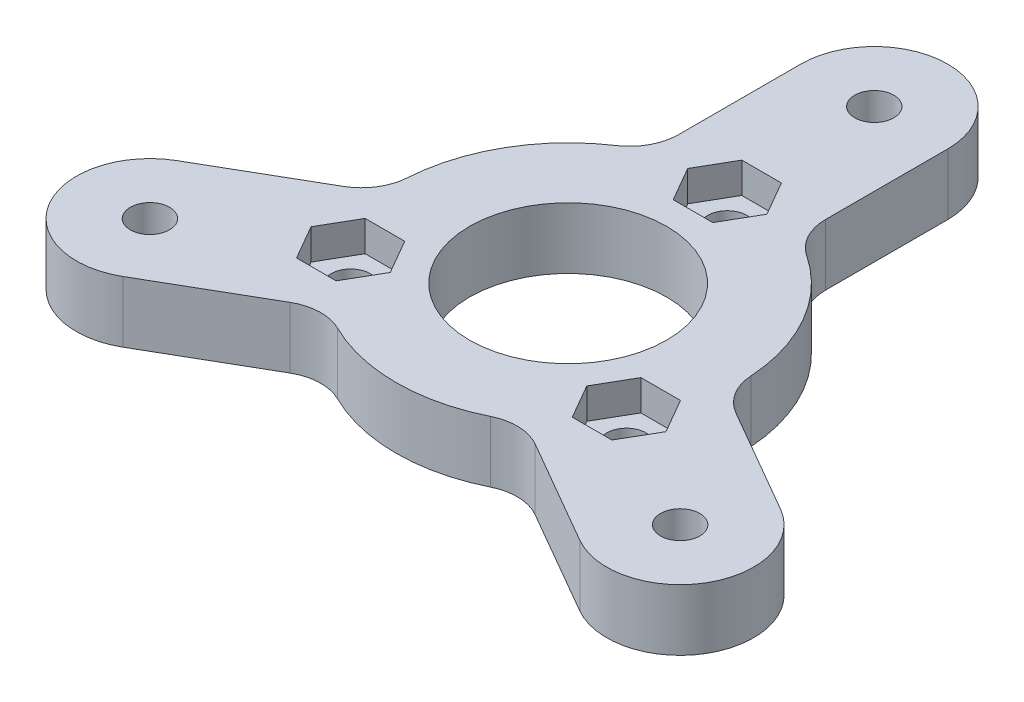
from build123d import *

# Parameters (mm, degrees)
SKETCH1_R           = 8.05
SKETCH1_R_2         = 1.6
BOSS_EXTRUDE1_DEPTH = 5
CUT_EXTRUDE1_DEPTH  = 2.5
CUT_EXTRUDE2_REACH  = 4.5
SKETCH4_R           = 1.6


with BuildPart() as part:
    # Sketch1 → Boss-Extrude1 (new body)
    with BuildSketch(Plane(origin=(0, 0, 0), x_dir=(1, 0, 0), z_dir=(0, 1, 0))):
        with BuildLine():
            Line((24.650635095, -7.303847577), (16.013526617, -2.317210672))
            ThreePointArc((16.013526617, -2.317210672), (14.614747196, -0.962208024), (14.021609361, 0.892732285))
            ThreePointArc((14.021609361, 0.892732285), (12.167656923, 7.025), (7.783933518, 11.696703766))
            ThreePointArc((7.783933518, 11.696703766), (6.474077005, 13.137846354), (6, 15.02672619))
            Line((6, 15.02672619), (6, 25))
            ThreePointArc((6, 25), (0, 31), (-6, 25))
            Line((-6, 25), (-6, 15.02672619))
            ThreePointArc((-6, 15.02672619), (-6.474077005, 13.137846354), (-7.783933518, 11.696703766))
            ThreePointArc((-7.783933518, 11.696703766), (-12.167656923, 7.025), (-14.021609361, 0.892732285))
            ThreePointArc((-14.021609361, 0.892732285), (-14.614747196, -0.962208024), (-16.013526617, -2.317210672))
            Line((-16.013526617, -2.317210672), (-24.650635095, -7.303847577))
            ThreePointArc((-24.650635095, -7.303847577), (-26.846787517, -15.5), (-18.650635095, -17.696152423))
            Line((-18.650635095, -17.696152423), (-10.013526617, -12.709515518))
            ThreePointArc((-10.013526617, -12.709515518), (-8.140670191, -12.17563833), (-6.237675843, -12.589436051))
            ThreePointArc((-6.237675843, -12.589436051), (0, -14.05), (6.237675843, -12.589436051))
            ThreePointArc((6.237675843, -12.589436051), (8.140670191, -12.17563833), (10.013526617, -12.709515518))
            Line((10.013526617, -12.709515518), (18.650635095, -17.696152423))
            ThreePointArc((18.650635095, -17.696152423), (26.846787517, -15.5), (24.650635095, -7.303847577))
        make_face()
        Circle(SKETCH1_R, mode=Mode.SUBTRACT)
        with Locations((0, 25)):
            Circle(SKETCH1_R_2, mode=Mode.SUBTRACT)
        with Locations((21.650635095, -12.5)):
            Circle(SKETCH1_R_2, mode=Mode.SUBTRACT)
        with Locations((-21.650635095, -12.5)):
            Circle(SKETCH1_R_2, mode=Mode.SUBTRACT)
    extrude(amount=BOSS_EXTRUDE1_DEPTH)

    # Sketch3 → Cut-Extrude1 (cut)
    with BuildSketch(Plane(origin=(0, 5, 0), x_dir=(1, 0, 0), z_dir=(0, 1, 0))):
        Polygon((1.616580754, 15.8), (-1.616580754, 15.8), (-3.233161507, 13), (-1.616580754, 10.2), (1.616580754, 10.2), (3.233161507, 13), align=None)
        Polygon((-8.025168742, -6.5), (-9.641749495, -3.7), (-12.874911003, -3.7), (-14.491491757, -6.5), (-12.874911003, -9.3), (-9.641749495, -9.3), align=None)
        Polygon((14.491491757, -6.5), (12.874911003, -3.7), (9.641749495, -3.7), (8.025168742, -6.5), (9.641749495, -9.3), (12.874911003, -9.3), align=None)
    extrude(amount=-CUT_EXTRUDE1_DEPTH, mode=Mode.SUBTRACT)

    # Sketch4 → Cut-Extrude2 (cut, up to next)
    with BuildSketch(Plane(origin=(0, 2.5, 0), x_dir=(1, 0, 0), z_dir=(0, 1, 0)), mode=Mode.PRIVATE) as cut_extrude2_sk1:
        with Locations((0, 13)):
            Circle(SKETCH4_R)
    cut_extrude2_tool1 = extrude(cut_extrude2_sk1.sketch, amount=-CUT_EXTRUDE2_REACH, mode=Mode.PRIVATE) & part.part
    add(cut_extrude2_tool1.solids().sort_by_distance((0, 2.5, -13))[0], mode=Mode.SUBTRACT)
    # Sketch4 → Cut-Extrude2 (cut, up to next)
    with BuildSketch(Plane(origin=(0, 2.5, 0), x_dir=(1, 0, 0), z_dir=(0, 1, 0)), mode=Mode.PRIVATE) as cut_extrude2_sk2:
        with Locations((11.258330249, -6.5)):
            Circle(SKETCH4_R)
    cut_extrude2_tool2 = extrude(cut_extrude2_sk2.sketch, amount=-CUT_EXTRUDE2_REACH, mode=Mode.PRIVATE) & part.part
    add(cut_extrude2_tool2.solids().sort_by_distance((11.25833, 2.5, 6.5))[0], mode=Mode.SUBTRACT)
    # Sketch4 → Cut-Extrude2 (cut, up to next)
    with BuildSketch(Plane(origin=(0, 2.5, 0), x_dir=(1, 0, 0), z_dir=(0, 1, 0)), mode=Mode.PRIVATE) as cut_extrude2_sk3:
        with Locations((-11.258330249, -6.5)):
            Circle(SKETCH4_R)
    cut_extrude2_tool3 = extrude(cut_extrude2_sk3.sketch, amount=-CUT_EXTRUDE2_REACH, mode=Mode.PRIVATE) & part.part
    add(cut_extrude2_tool3.solids().sort_by_distance((-11.25833, 2.5, 6.5))[0], mode=Mode.SUBTRACT)


solid = part.part
